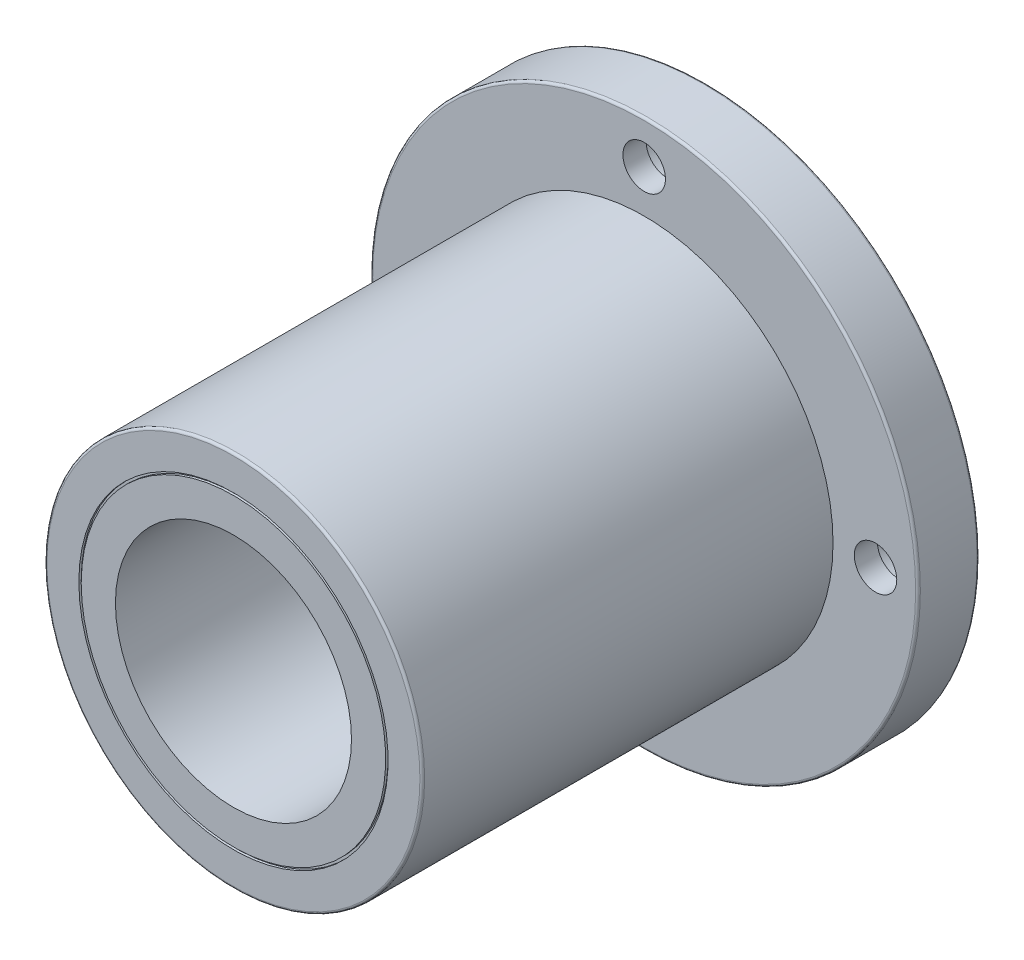
from build123d import *

# Parameters (mm, degrees)
PADR_OCIRCULAR1_COUNT = 4
FILETE1_R             = 0.5


with BuildPart() as part:
    # Esboço1 → Revolução1 (revolve)
    with BuildSketch(Plane(origin=(0, 0, 0), x_dir=(0, 0, -1), z_dir=(1, 0, 0)), mode=Mode.PRIVATE) as revolu_o1_sk:
        Polygon((0, 25), (0, 32.25), (-0.5, 32.25), (-0.5, 32.75), (0, 32.75), (0, 39.5), (-0.5, 39.5), (-0.5, 40), (0, 40), (0, 58), (-13, 58), (-13, 40), (-100, 40), (-100, 32.75), (-99.5, 32.75), (-99.5, 32.25), (-100, 32.25), (-100, 25), align=None)
    revolve(revolu_o1_sk.sketch.rotate(Axis((0, 0, 0), (0, 0, 1)), 90), axis=Axis((0, 0, 0), (0, 0, 1)))  # turned: the seam where the file's is

    # Esboço5 → Corte-Revolução1 (revolve, cut)
    with BuildSketch(Plane(origin=(0, 0, 0), x_dir=(0, 0, -1), z_dir=(1, 0, 0)), mode=Mode.PRIVATE) as corte_revolu_o1_sk:
        Polygon((0, 56), (-8.1, 56), (-8.1, 53.5), (-13, 53.5), (-13, 49), (0, 49), align=None)
    corte_revolu_o1 = revolve(corte_revolu_o1_sk.sketch.rotate(Axis((0, 49, 0), (0, 0, -1)), 90), axis=Axis((0, 49, 0), (0, 0, -1)), mode=Mode.SUBTRACT)  # turned: the seam where the file's is

    # PadrãoCircular1: Corte-Revolução1 ×4 about axis
    padr_ocircular1_axis = Axis((0, 0, 0), (0, 0, 1))
    for i in range(1, PADR_OCIRCULAR1_COUNT):
        add(corte_revolu_o1.rotate(padr_ocircular1_axis, i * 360 / PADR_OCIRCULAR1_COUNT), mode=Mode.SUBTRACT)

    # Filete1
    filete1_edges = [part.edges().sort_by_distance(p)[0] for p in [
        (40, 0, 100),
        (58, 0, 13),
        (58, 0, 0),
    ]]
    fillet(filete1_edges, radius=FILETE1_R)


solid = part.part
